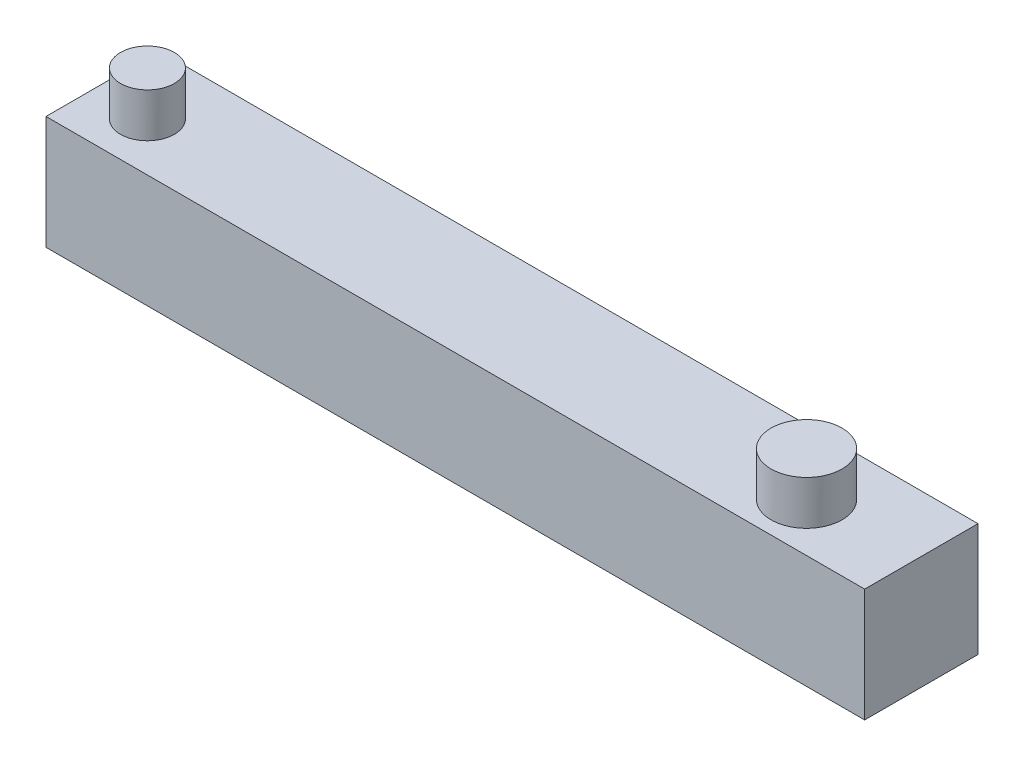
from build123d import *

# Parameters (mm, degrees)
SKETCH1_W           = 65
SKETCH1_H           = 9
BOSS_EXTRUDE1_DEPTH = 9
SKETCH2_R           = 2.135801536
SKETCH2_R_2         = 2.816522171
BOSS_EXTRUDE2_DEPTH = 3.5


with BuildPart() as part:
    # Sketch1 → Boss-Extrude1 (new body)
    with BuildSketch(Plane.XY):
        with Locations((32.5, 4.5)):
            Rectangle(SKETCH1_W, SKETCH1_H)
    extrude(amount=BOSS_EXTRUDE1_DEPTH)

    # Sketch2 → Boss-Extrude2 (add)
    with BuildSketch(Plane(origin=(0, 9, 0), x_dir=(1, 0, 0), z_dir=(0, 1, 0))):
        with Locations(Location((4.190880533, -5.138095646, 0), (0, 0, 90))):  # turned: the seam where the file's is
            Circle(SKETCH2_R)
        with Locations(Location((56.526848016, -5.138095646, 0), (0, 0, 90))):  # turned: the seam where the file's is
            Circle(SKETCH2_R_2)
    extrude(amount=BOSS_EXTRUDE2_DEPTH)


solid = part.part
